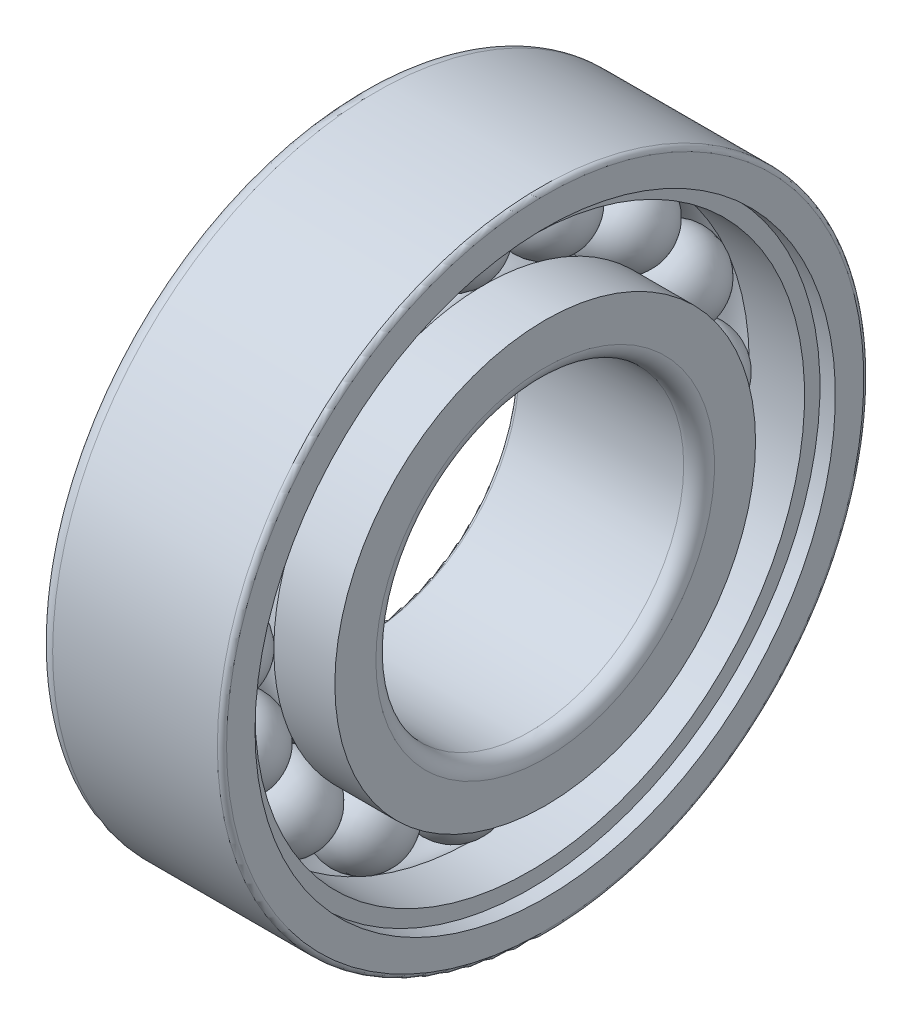
from build123d import *

# Parameters (mm, degrees)
CIRCULAR_PATTERN1_COUNT = 16
FILLET1_R               = 1
FILLET2_R               = 0.3


with BuildPart() as part:
    # Sketch1 → Revolve1 (revolve)
    with BuildSketch(Plane.XY):
        with BuildLine():
            Line((-2.75, 15.5), (2.75, 15.5))
            ThreePointArc((2.75, 15.5), (0, 12.75), (-2.75, 15.5))
        make_face()
    revolve1 = revolve(axis=Axis((-3.091912561, 15.5, 0), (1, 0, 0)))

    # Sketch2 → Revolve2 (revolve)
    with BuildSketch(Plane.XY):
        with BuildLine():
            Line((-6, 13.666666667), (-2.036292928, 13.666666667))
            ThreePointArc((-2.036292928, 13.666666667), (0, 12.76), (2.036292928, 13.666666667))
            Line((2.036292928, 13.666666667), (6, 13.666666667))
            Line((6, 13.666666667), (6, 10))
            Line((6, 10), (-6, 10))
            Line((-6, 10), (-6, 13.666666667))
        make_face()
    revolve(axis=Axis((-2.992358943, 0, 0), (1, 0, 0)))

    # Sketch3 → Revolve3 (revolve)
    with BuildSketch(Plane.XY):
        with BuildLine():
            Line((-6, 17.333333333), (-6, 21))
            Line((-6, 21), (6, 21))
            Line((6, 21), (6, 18.853333333))
            Line((6, 18.853333333), (5, 18.853333333))
            Line((5, 18.853333333), (5, 17.853333333))
            Line((5, 17.853333333), (1.403361045, 17.853333333))
            ThreePointArc((1.403361045, 17.853333333), (-0.409573793, 18.209215626), (-2.036292928, 17.333333333))
            Line((-2.036292928, 17.333333333), (-6, 17.333333333))
        make_face()
    revolve(axis=Axis((-2.992358943, 0, 0), (1, 0, 0)))

    # Circular-Pattern1: Revolve1 ×16 about axis
    circular_pattern1_axis = Axis((0, 0, 0), (1, 0, 0))
    for i in range(1, CIRCULAR_PATTERN1_COUNT):
        add(revolve1.rotate(circular_pattern1_axis, i * 360 / CIRCULAR_PATTERN1_COUNT))

    # Fillet1
    fillet1_edges = [part.edges().sort_by_distance(p)[0] for p in [
        (-6, -21, 0),
        (6, -10, 0),
    ]]
    fillet(fillet1_edges, radius=FILLET1_R)

    # Fillet2
    fillet2_edges = [part.edges().sort_by_distance(p)[0] for p in [
        (6, -21, 0),
        (-6, -10, 0),
    ]]
    fillet(fillet2_edges, radius=FILLET2_R)


solid = part.part
